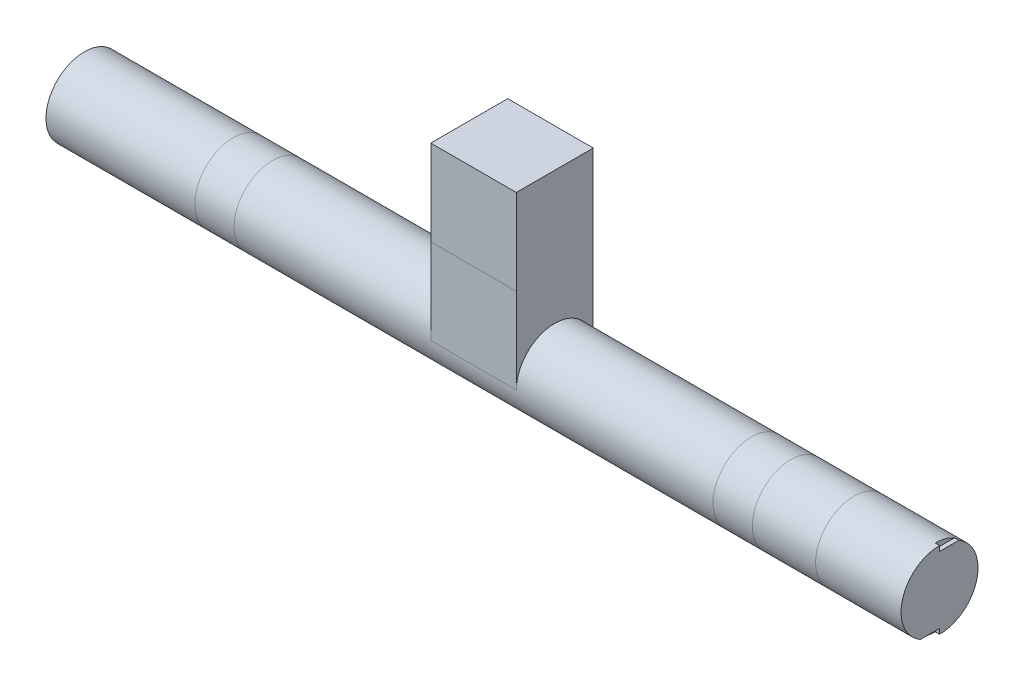
from build123d import *

# Parameters (mm, degrees)
ESQUISSE1_R             = 45
BOSS_EXTRU_1_DEPTH      = 500
ESQUISSE2_W             = 90
ESQUISSE2_H             = 200
BOSS_EXTRU_2_DEPTH      = 50
ESQUISSE7_W             = 22.449944321
ESQUISSE7_H             = 6
ENL_V_MAT_EXTRU_1_DEPTH = 5


with BuildPart() as part:
    # Esquisse1 → Boss.-Extru.1 (new body, symmetric)
    with BuildSketch(Plane(origin=(0, 0, 0), x_dir=(0, 0, -1), z_dir=(1, 0, 0))):
        Circle(ESQUISSE1_R)
    extrude(amount=BOSS_EXTRU_1_DEPTH, both=True)

    # Esquisse2 → Boss.-Extru.2 (add, symmetric)
    with BuildSketch(Plane(origin=(0, 0, 0), x_dir=(0, 0, -1), z_dir=(1, 0, 0))):
        with Locations((0, 100)):
            Rectangle(ESQUISSE2_W, ESQUISSE2_H)
    extrude(amount=BOSS_EXTRU_2_DEPTH, both=True)

    # Esquisse7 → Enlèv. mat.-Extru.1 (cut)
    with BuildSketch(Plane(origin=(500, 0, 0), x_dir=(0, 0, -1), z_dir=(1, 0, 0))):
        with Locations((11.224972161, 42)):
            Rectangle(ESQUISSE7_W, ESQUISSE7_H)
        with Locations((-11.224972161, -42)):
            Rectangle(ESQUISSE7_W, ESQUISSE7_H)
    extrude(amount=-ENL_V_MAT_EXTRU_1_DEPTH, mode=Mode.SUBTRACT)


solid = part.part
